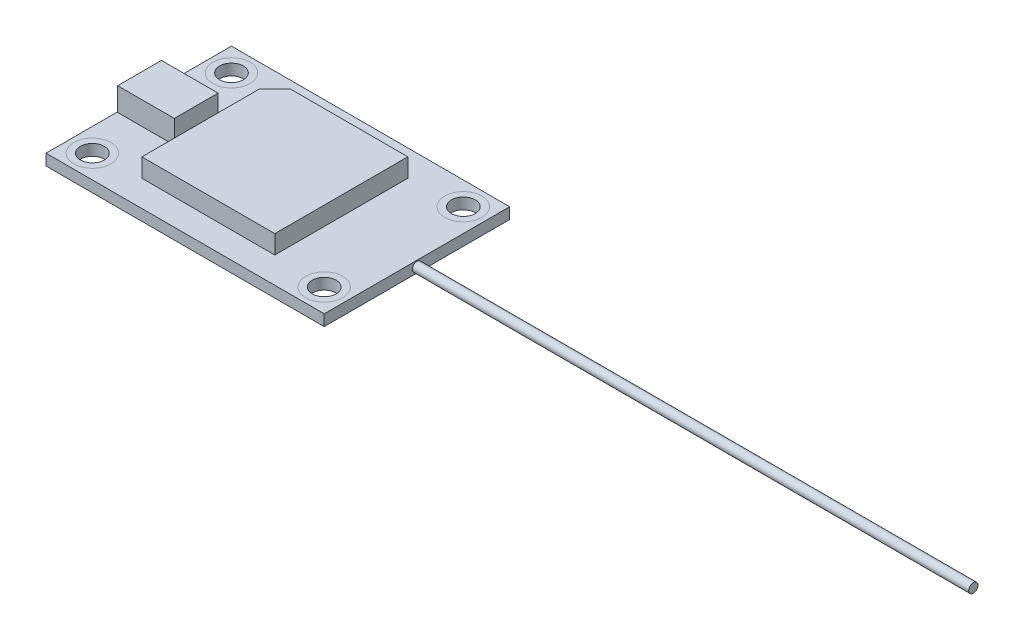
from build123d import *

# Parameters (mm, degrees)
SKETCH1_W             = 38.1
SKETCH1_H             = 25.4
BOSS_EXTRUDE1_DEPTH   = 1.524
F_4_CLEARANCE_HOLE1_D = 3.2639
BOSS_EXTRUDE2_DEPTH   = 2.54
SKETCH2_3_W           = 7.759657213
SKETCH2_3_H           = 5.99739549
BOSS_EXTRUDE3_DEPTH   = 3.175
SKETCH6_R             = 0.635
BOSS_EXTRUDE4_DEPTH   = 76.2


with BuildPart() as part:
    # Sketch1 → Boss-Extrude1 (new body)
    with BuildSketch(Plane(origin=(0, 0, 0), x_dir=(1, 0, 0), z_dir=(0, 1, 0))):
        Rectangle(SKETCH1_W, SKETCH1_H)
    extrude(amount=BOSS_EXTRUDE1_DEPTH)

    # 4 Clearance Hole1 (through all)
    with Locations(Plane(origin=(0, 1.524, 0), x_dir=(1, 0, 0), z_dir=(0, 1, 0))):
        with Locations((-15.875, 9.525), (15.875, 9.525), (15.875, -9.525), (-15.875, -9.525)):
            Hole(F_4_CLEARANCE_HOLE1_D / 2)

    # Sketch2 → Boss-Extrude2 (add)
    with BuildSketch(Plane(origin=(0, 1.524, 0), x_dir=(1, 0, 0), z_dir=(0, 1, 0))):
        Polygon((-9.50810694, -9.112699607), (8.695477597, -9.112699607), (8.695477597, 9.104771495), (-7.397734973, 9.104771495), (-9.50810694, 6.994399527), align=None)
    extrude(amount=BOSS_EXTRUDE2_DEPTH)

    # Sketch2_3 → Boss-Extrude3 (add)
    with BuildSketch(Plane(origin=(0, 1.524, 0), x_dir=(1, 0, 0), z_dir=(0, 1, 0))):
        with Locations((-15.092977225, 0.033144474)):
            Rectangle(SKETCH2_3_W, SKETCH2_3_H)
    extrude(amount=BOSS_EXTRUDE3_DEPTH)

    # Sketch6 → Boss-Extrude4 (add)
    with BuildSketch(Plane(origin=(19.05, 0, 0), x_dir=(0, 0, -1), z_dir=(1, 0, 0))):
        with Locations((0, 0.762)):
            Circle(SKETCH6_R)
    extrude(amount=BOSS_EXTRUDE4_DEPTH)


solid = part.part
